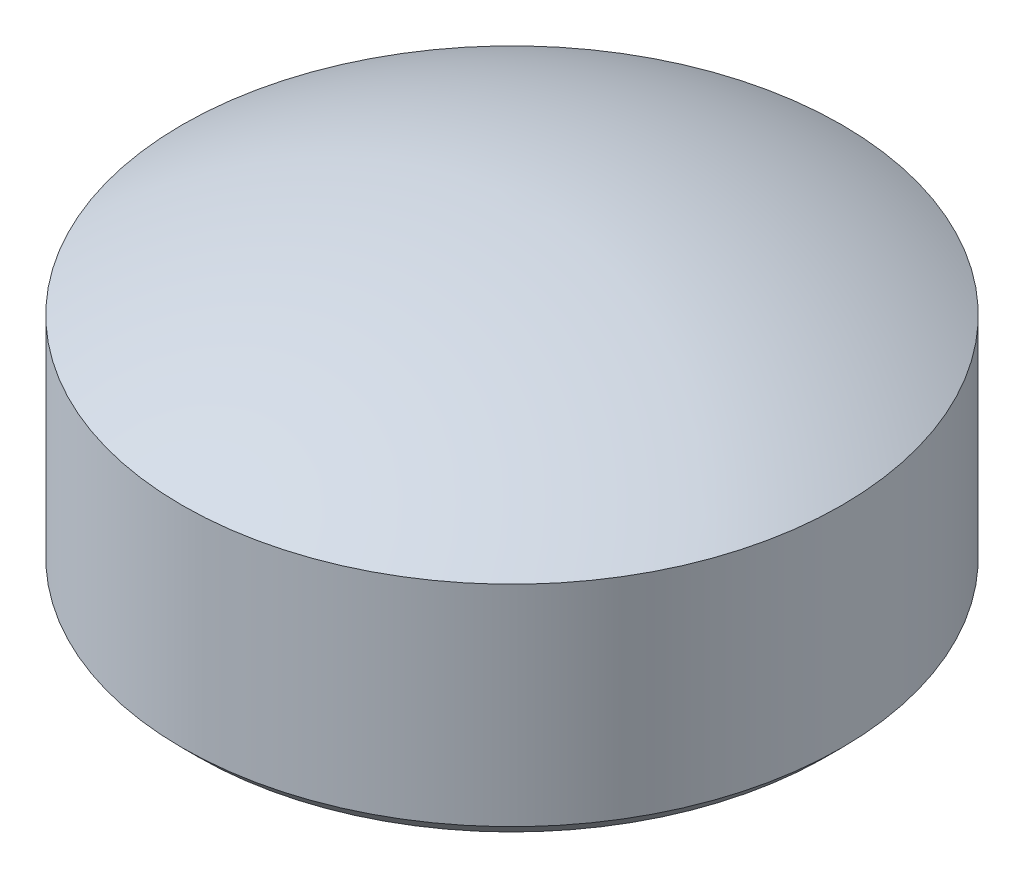
from build123d import *

# Parameters (mm, degrees)
CUT_EXTRUDE1_DEPTH      = 32.670175244
CUT_EXTRUDE1_DEPTH_BACK = 32.670175244
SKETCH2_R               = 21
SKETCH2_R_2             = 10.5
SKETCH2_5_R             = 10.5
CUT_EXTRUDE2_DEPTH      = 19.479718613
CHAMFER1_SIZE           = 0.5


with BuildPart() as part:
    # Sketch1 → Revolve1 (revolve)
    with BuildSketch(Plane.XY):
        with BuildLine():
            Line((0, 10), (0, -11))
            Line((0, -11), (-21, -11))
            ThreePointArc((-21, -11), (-14.849242405, 3.849242405), (0, 10))
        make_face()
    revolve(axis=Axis((0, 10, 0), (0, -1, 0)))

    # Sketch2 → Cut-Extrude1 (cut, two sides: drawn at the far end of the back side and taken through both)
    with BuildSketch(Plane(origin=(0, 0, 0), x_dir=(1, 0, 0), z_dir=(0, 1, 0)).offset(-CUT_EXTRUDE1_DEPTH_BACK)):
        Circle(SKETCH2_R)
        Circle(SKETCH2_R_2, mode=Mode.SUBTRACT)
    extrude(amount=CUT_EXTRUDE1_DEPTH + CUT_EXTRUDE1_DEPTH_BACK, mode=Mode.SUBTRACT)

    # Sketch2_5 → Cut-Extrude2 (cut, through all)
    with BuildSketch(Plane(origin=(0, 0, 0), x_dir=(1, 0, 0), z_dir=(0, 1, 0))):
        Circle(SKETCH2_5_R)
    extrude(amount=-CUT_EXTRUDE2_DEPTH, mode=Mode.SUBTRACT)

    # Chamfer1
    chamfer1_edges = [part.edges().sort_by_distance(p)[0] for p in [
        (-10.5, 0, 0),
    ]]
    chamfer(chamfer1_edges, length=CHAMFER1_SIZE)


solid = part.part
